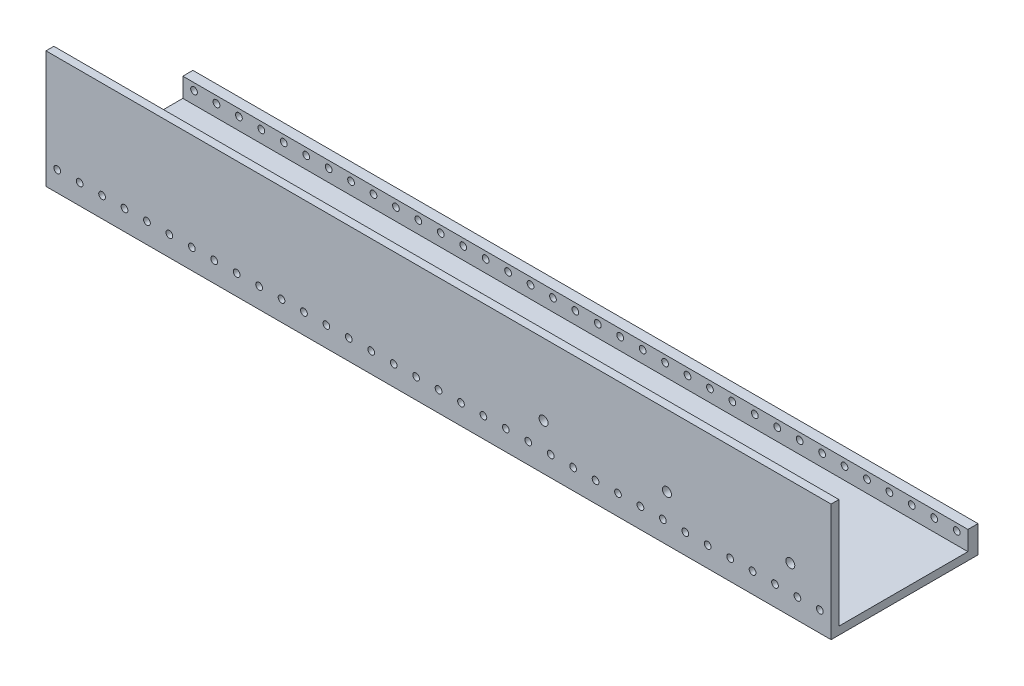
from build123d import *

# Parameters (mm, degrees)
SKETCH1_W           = 3500
SKETCH1_H           = 700
BOSS_EXTRUDE1_DEPTH = 35
SKETCH2_R           = 15
CUT_EXTRUDE1_DEPTH  = 36
EXTRUDE_THIN1_DEPTH = 3500
SKETCH4_R           = 15
CUT_EXTRUDE2_DEPTH  = 646
SKETCH6_W           = 3500
SKETCH6_H           = 104.864129743
SKETCH6_H_2         = 490.271740514
CUT_EXTRUDE4_DEPTH  = 80
SKETCH7_W           = 3500
SKETCH7_H           = 139.864129743
BOSS_EXTRUDE2_DEPTH = 10
SKETCH8_R           = 15
SKETCH8_W           = 100
SKETCH8_H           = 90.456234172
BOSS_EXTRUDE3_DEPTH = 15
SKETCH10_R          = 15
BOSS_EXTRUDE4_DEPTH = 20
SKETCH14_R          = 15
BOSS_EXTRUDE6_DEPTH = 20
SKETCH15_W          = 45.272663703
SKETCH15_H          = 22.376664335
CUT_EXTRUDE5_DEPTH  = 3501
SKETCH16_R          = 20
CUT_EXTRUDE6_DEPTH  = 36
SKETCH17_R          = 20
CUT_EXTRUDE7_DEPTH  = 36
SKETCH18_W          = 3500
SKETCH18_H          = 211.2993835
CUT_EXTRUDE8_DEPTH  = 36


with BuildPart() as part:
    # Sketch1 → Boss-Extrude1 (new body)
    with BuildSketch(Plane.XY):
        Rectangle(SKETCH1_W, SKETCH1_H)
    extrude(amount=BOSS_EXTRUDE1_DEPTH)

    # Sketch2 → Cut-Extrude1 (cut, through all)
    with BuildSketch(Plane.XY.offset(35)):
        with Locations((-1700, -295)):
            Circle(SKETCH2_R)
        with Locations((-1600, -295)):
            Circle(SKETCH2_R)
        with Locations((-1500, -295)):
            Circle(SKETCH2_R)
        with Locations((-1400, -295)):
            Circle(SKETCH2_R)
        with Locations((-1300, -295)):
            Circle(SKETCH2_R)
        with Locations((-1200, -295)):
            Circle(SKETCH2_R)
        with Locations((-1100, -295)):
            Circle(SKETCH2_R)
        with Locations((-1000, -295)):
            Circle(SKETCH2_R)
        with Locations((-900, -295)):
            Circle(SKETCH2_R)
        with Locations((-800, -295)):
            Circle(SKETCH2_R)
        with Locations((-700, -295)):
            Circle(SKETCH2_R)
        with Locations((-600, -295)):
            Circle(SKETCH2_R)
        with Locations((-500, -295)):
            Circle(SKETCH2_R)
        with Locations((-400, -295)):
            Circle(SKETCH2_R)
        with Locations((-300, -295)):
            Circle(SKETCH2_R)
        with Locations((-200, -295)):
            Circle(SKETCH2_R)
        with Locations((-100, -295)):
            Circle(SKETCH2_R)
        with Locations((100, -295)):
            Circle(SKETCH2_R)
        with Locations((200, -295)):
            Circle(SKETCH2_R)
        with Locations((300, -295)):
            Circle(SKETCH2_R)
        with Locations((400, -295)):
            Circle(SKETCH2_R)
        with Locations((500, -295)):
            Circle(SKETCH2_R)
        with Locations((600, -295)):
            Circle(SKETCH2_R)
        with Locations((700, -295)):
            Circle(SKETCH2_R)
        with Locations((800, -295)):
            Circle(SKETCH2_R)
        with Locations((900, -295)):
            Circle(SKETCH2_R)
        with Locations((1000, -295)):
            Circle(SKETCH2_R)
        with Locations((1100, -295)):
            Circle(SKETCH2_R)
        with Locations((1200, -295)):
            Circle(SKETCH2_R)
        with Locations((1300, -295)):
            Circle(SKETCH2_R)
        with Locations((1400, -295)):
            Circle(SKETCH2_R)
        with Locations((1500, -295)):
            Circle(SKETCH2_R)
        with Locations((1600, -295)):
            Circle(SKETCH2_R)
        with Locations((1700, -295)):
            Circle(SKETCH2_R)
        with Locations((0, -295)):
            Circle(SKETCH2_R)
    extrude(amount=-CUT_EXTRUDE1_DEPTH, mode=Mode.SUBTRACT)

    # Sketch3 → Extrude-Thin1 (add)
    with BuildSketch(Plane.ZY.offset(1750)):
        Polygon((0, -350), (610, -350), (610, 350), (645, 350), (645, -385), (0, -385), align=None)
    extrude(amount=-EXTRUDE_THIN1_DEPTH)

    # Sketch4 → Cut-Extrude2 (cut, through all)
    with BuildSketch(Plane.XY.offset(645)):
        with Locations((-1700, -295)):
            Circle(SKETCH4_R)
        with Locations((-1600, -295)):
            Circle(SKETCH4_R)
        with Locations((-1500, -295)):
            Circle(SKETCH4_R)
        with Locations((-1400, -295)):
            Circle(SKETCH4_R)
        with Locations((-1300, -295)):
            Circle(SKETCH4_R)
        with Locations((-1200, -295)):
            Circle(SKETCH4_R)
        with Locations((-1100, -295)):
            Circle(SKETCH4_R)
        with Locations((-1000, -295)):
            Circle(SKETCH4_R)
        with Locations((-900, -295)):
            Circle(SKETCH4_R)
        with Locations((-800, -295)):
            Circle(SKETCH4_R)
        with Locations((-700, -295)):
            Circle(SKETCH4_R)
        with Locations((-600, -295)):
            Circle(SKETCH4_R)
        with Locations((-500, -295)):
            Circle(SKETCH4_R)
        with Locations((-400, -295)):
            Circle(SKETCH4_R)
        with Locations((-300, -295)):
            Circle(SKETCH4_R)
        with Locations((-200, -295)):
            Circle(SKETCH4_R)
        with Locations((-100, -295)):
            Circle(SKETCH4_R)
        with Locations((0, -295)):
            Circle(SKETCH4_R)
        with Locations((100, -295)):
            Circle(SKETCH4_R)
        with Locations((200, -295)):
            Circle(SKETCH4_R)
        with Locations((300, -295)):
            Circle(SKETCH4_R)
        with Locations((400, -295)):
            Circle(SKETCH4_R)
        with Locations((500, -295)):
            Circle(SKETCH4_R)
        with Locations((600, -295)):
            Circle(SKETCH4_R)
        with Locations((700, -295)):
            Circle(SKETCH4_R)
        with Locations((800, -295)):
            Circle(SKETCH4_R)
        with Locations((900, -295)):
            Circle(SKETCH4_R)
        with Locations((1000, -295)):
            Circle(SKETCH4_R)
        with Locations((1100, -295)):
            Circle(SKETCH4_R)
        with Locations((1200, -295)):
            Circle(SKETCH4_R)
        with Locations((1300, -295)):
            Circle(SKETCH4_R)
        with Locations((1400, -295)):
            Circle(SKETCH4_R)
        with Locations((1500, -295)):
            Circle(SKETCH4_R)
        with Locations((1600, -295)):
            Circle(SKETCH4_R)
        with Locations((1700, -295)):
            Circle(SKETCH4_R)
    extrude(amount=-CUT_EXTRUDE2_DEPTH, mode=Mode.SUBTRACT)

    # Sketch6 → Cut-Extrude4 (cut)
    with BuildSketch(Plane(origin=(0, 0, 0), x_dir=(-1, 0, 0), z_dir=(0, 0, -1))):
        with Locations((0, 297.567935129)):
            Rectangle(SKETCH6_W, SKETCH6_H)
        Rectangle(SKETCH6_W, SKETCH6_H_2)
    extrude(amount=-CUT_EXTRUDE4_DEPTH, mode=Mode.SUBTRACT)

    # Sketch7 → Boss-Extrude2 (add)
    with BuildSketch(Plane(origin=(0, 0, 0), x_dir=(-1, 0, 0), z_dir=(0, 0, -1))):
        with Locations((0, -315.067935129)):
            Rectangle(SKETCH7_W, SKETCH7_H)
    extrude(amount=BOSS_EXTRUDE2_DEPTH)

    # Sketch8 → Boss-Extrude3 (add)
    with BuildSketch(Plane(origin=(0, 0, 610), x_dir=(-1, 0, 0), z_dir=(0, 0, -1))):
        Polygon((531.713934858, -29.74996251), (531.713934858, 62), (431.713934858, 62), (431.713934858, -32), (431.713934858, -232), (531.713934858, -232), align=None)
        with Locations((481.713934858, -185)):
            Circle(SKETCH8_R, mode=Mode.SUBTRACT)
        with Locations((481.713934858, 15)):
            Circle(SKETCH8_R, mode=Mode.SUBTRACT)
        with Locations((481.713934858, -85.997367662)):
            Circle(SKETCH8_R, mode=Mode.SUBTRACT)
        with Locations((-218.286065142, -186.771882914)):
            Rectangle(SKETCH8_W, SKETCH8_H)
        with Locations((-218.286065142, -185)):
            Circle(SKETCH8_R, mode=Mode.SUBTRACT)
        with Locations((-768.286065142, -186.771882914)):
            Rectangle(SKETCH8_W, SKETCH8_H)
        with Locations((-768.286065142, -185)):
            Circle(SKETCH8_R, mode=Mode.SUBTRACT)
        with Locations((-1318.286065142, -186.771882914)):
            Rectangle(SKETCH8_W, SKETCH8_H)
        with Locations((-1318.286065142, -185)):
            Circle(SKETCH8_R, mode=Mode.SUBTRACT)
    extrude(amount=BOSS_EXTRUDE3_DEPTH)

    # Sketch10 → Boss-Extrude4 (add)
    with BuildSketch(Plane(origin=(0, 0, 610), x_dir=(-1, 0, 0), z_dir=(0, 0, -1))):
        with Locations((481.713934858, 15)):
            Circle(SKETCH10_R)
        with Locations((481.713934858, -185)):
            Circle(SKETCH10_R)
        with Locations((481.713934858, -85.997367662)):
            Circle(SKETCH10_R)
    extrude(amount=BOSS_EXTRUDE4_DEPTH)

    # Sketch14 → Boss-Extrude6 (add)
    with BuildSketch(Plane(origin=(0, 0, 610), x_dir=(-1, 0, 0), z_dir=(0, 0, -1))):
        with Locations((-768.286065142, -185)):
            Circle(SKETCH14_R)
        with Locations((-1318.286065142, -185)):
            Circle(SKETCH14_R)
        with Locations((-218.286065142, -185)):
            Circle(SKETCH14_R)
    extrude(amount=BOSS_EXTRUDE6_DEPTH)

    # Sketch15 → Cut-Extrude5 (cut, through all)
    with BuildSketch(Plane.ZY.offset(1750)):
        with Locations((12.363668149, -252.963536078)):
            Rectangle(SKETCH15_W, SKETCH15_H)
    extrude(amount=-CUT_EXTRUDE5_DEPTH, mode=Mode.SUBTRACT)

    # Sketch16 → Cut-Extrude6 (cut, through all)
    with BuildSketch(Plane(origin=(0, 0, 610), x_dir=(-1, 0, 0), z_dir=(0, 0, -1))):
        with Locations((-468.286065142, -180)):
            Circle(SKETCH16_R)
    extrude(amount=-CUT_EXTRUDE6_DEPTH, mode=Mode.SUBTRACT)

    # Sketch17 → Cut-Extrude7 (cut, through all)
    with BuildSketch(Plane(origin=(0, 0, 610), x_dir=(-1, 0, 0), z_dir=(0, 0, -1))):
        with Locations((-1018.286065142, -180)):
            Circle(SKETCH17_R)
        with Locations((-1568.171386268, -180)):
            Circle(SKETCH17_R)
    extrude(amount=-CUT_EXTRUDE7_DEPTH, mode=Mode.SUBTRACT)

    # Sketch18 → Cut-Extrude8 (cut, through all)
    with BuildSketch(Plane(origin=(0, 0, 610), x_dir=(-1, 0, 0), z_dir=(0, 0, -1))):
        with Locations((0, 244.35030825)):
            Rectangle(SKETCH18_W, SKETCH18_H)
    extrude(amount=-CUT_EXTRUDE8_DEPTH, mode=Mode.SUBTRACT)


solid = part.part
